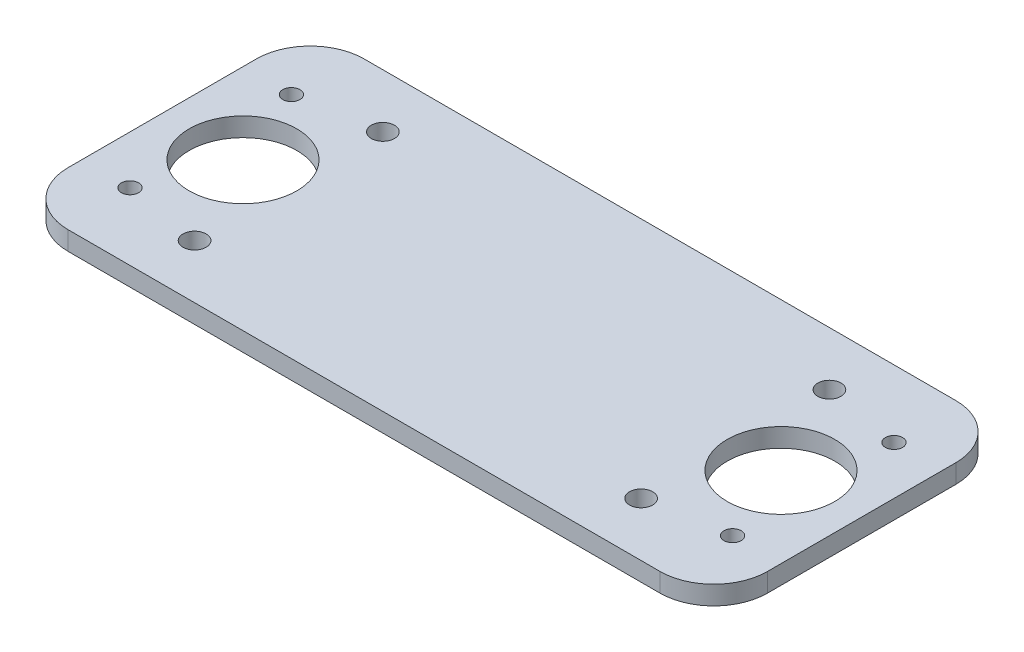
from build123d import *

# Parameters (mm, degrees)
SKETCH1_W           = 130
SKETCH1_H           = 55
SKETCH1_R           = 1.6
SKETCH1_R_2         = 10
SKETCH1_R_3         = 2.15
BOSS_EXTRUDE2_DEPTH = 3.5
FILLET2_R           = 10


with BuildPart() as part:
    # Sketch1 → Boss-Extrude2 (new body)
    with BuildSketch(Plane(origin=(0, 0, 0), x_dir=(1, 0, 0), z_dir=(0, 1, 0))):
        with Locations((65, -27.5)):
            Rectangle(SKETCH1_W, SKETCH1_H)
        with Locations((9, -12.5)):
            Circle(SKETCH1_R, mode=Mode.SUBTRACT)
        with Locations((9, -42.5)):
            Circle(SKETCH1_R, mode=Mode.SUBTRACT)
        with Locations((121, -42.5)):
            Circle(SKETCH1_R, mode=Mode.SUBTRACT)
        with Locations((121, -12.5)):
            Circle(SKETCH1_R, mode=Mode.SUBTRACT)
        with Locations((15, -27.5)):
            Circle(SKETCH1_R_2, mode=Mode.SUBTRACT)
        with Locations((115, -27.5)):
            Circle(SKETCH1_R_2, mode=Mode.SUBTRACT)
        with Locations((106.5, -10)):
            Circle(SKETCH1_R_3, mode=Mode.SUBTRACT)
        with Locations((106.5, -45)):
            Circle(SKETCH1_R_3, mode=Mode.SUBTRACT)
        with Locations((23.5, -45)):
            Circle(SKETCH1_R_3, mode=Mode.SUBTRACT)
        with Locations((23.5, -10)):
            Circle(SKETCH1_R_3, mode=Mode.SUBTRACT)
    extrude(amount=BOSS_EXTRUDE2_DEPTH)

    # Fillet2
    fillet2_edges = [part.edges().sort_by_distance(p)[0] for p in [
        (0, 1.75, 0),
        (130, 1.75, 0),
        (130, 1.75, 55),
        (0, 1.75, 55),
    ]]
    fillet(fillet2_edges, radius=FILLET2_R)


solid = part.part
